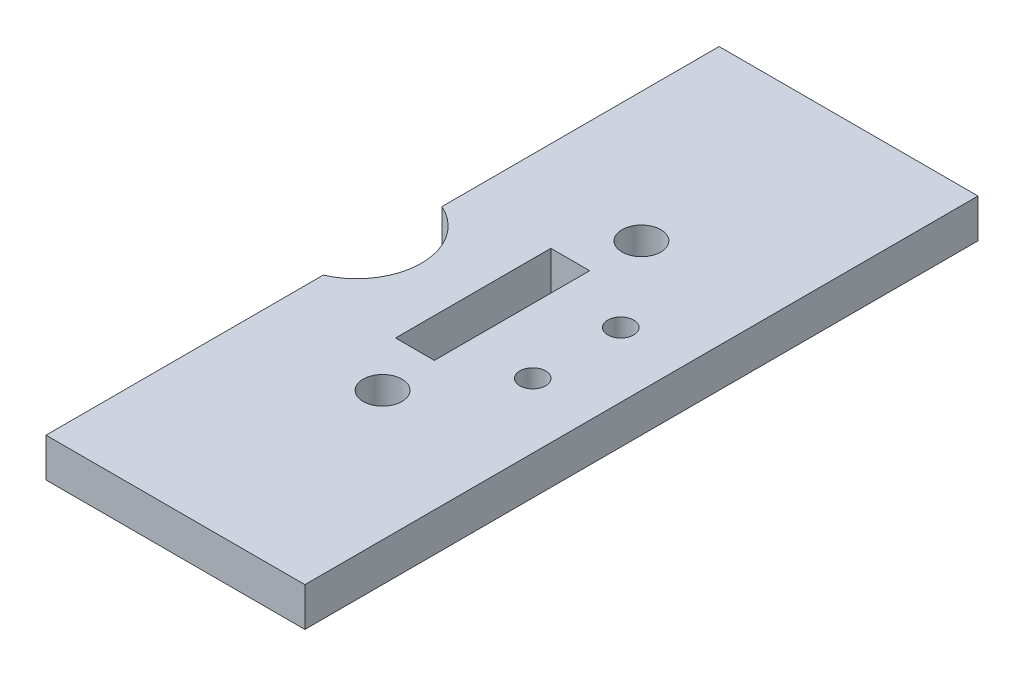
from build123d import *

# Parameters (mm, degrees)
ESQUISSE1_W             = 20
ESQUISSE1_H             = 52
BOSS_EXTRU_1_DEPTH      = 3
ESQUISSE2_R             = 1.5
ENL_V_MAT_EXTRU_1_DEPTH = 3
ESQUISSE3_R             = 5
ENL_V_MAT_EXTRU_2_DEPTH = 3
ESQUISSE4_W             = 3
ESQUISSE4_H             = 12
ENL_V_MAT_EXTRU_3_DEPTH = 10
ESQUISSE5_R             = 1
ENL_V_MAT_EXTRU_5_DEPTH = 10


with BuildPart() as part:
    # Esquisse1 → Boss.-Extru.1 (new body)
    with BuildSketch(Plane(origin=(0, 0, 0), x_dir=(1, 0, 0), z_dir=(0, 1, 0))):
        with Locations((-11.986036915, -31.933409069)):
            Rectangle(ESQUISSE1_W, ESQUISSE1_H)
    extrude(amount=BOSS_EXTRU_1_DEPTH)

    # Esquisse2 → Enlèv. mat.-Extru.1 (cut)
    with BuildSketch(Plane(origin=(0, 3, 0), x_dir=(1, 0, 0), z_dir=(0, 1, 0))):
        with Locations((-11.986036915, -41.933409069)):
            Circle(ESQUISSE2_R)
        with Locations((-11.986036915, -21.933409069)):
            Circle(ESQUISSE2_R)
    extrude(amount=-ENL_V_MAT_EXTRU_1_DEPTH, mode=Mode.SUBTRACT)

    # Esquisse3 → Enlèv. mat.-Extru.2 (cut)
    with BuildSketch(Plane(origin=(0, 3, 0), x_dir=(1, 0, 0), z_dir=(0, 1, 0))):
        with Locations((-23.986036915, -31.933409069)):
            Circle(ESQUISSE3_R)
    extrude(amount=-ENL_V_MAT_EXTRU_2_DEPTH, mode=Mode.SUBTRACT)

    # Esquisse4 → Enlèv. mat.-Extru.3 (cut)
    with BuildSketch(Plane(origin=(0, 3, 0), x_dir=(1, 0, 0), z_dir=(0, 1, 0))):
        with Locations((-13.486036915, -31.930984764)):
            Rectangle(ESQUISSE4_W, ESQUISSE4_H)
    extrude(amount=-ENL_V_MAT_EXTRU_3_DEPTH, mode=Mode.SUBTRACT)

    # Esquisse5 → Enlèv. mat.-Extru.5 (cut)
    with BuildSketch(Plane(origin=(0, 3, 0), x_dir=(1, 0, 0), z_dir=(0, 1, 0))):
        with Locations((-6.986036915, -35.330984764)):
            Circle(ESQUISSE5_R)
        with Locations((-6.986036915, -28.530984764)):
            Circle(ESQUISSE5_R)
    extrude(amount=-ENL_V_MAT_EXTRU_5_DEPTH, mode=Mode.SUBTRACT)


solid = part.part
